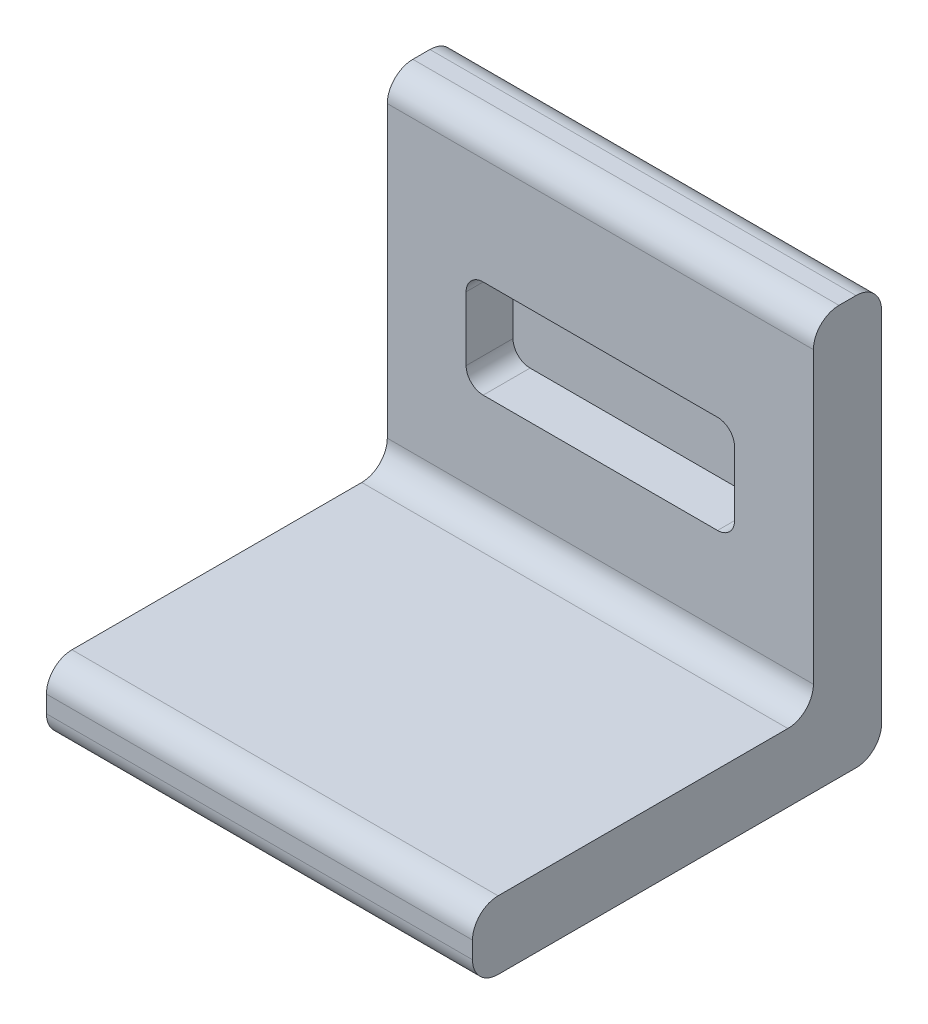
from build123d import *

# Parameters (mm, degrees)
SKETCH1_W           = 50
SKETCH1_H           = 40
BOSS_EXTRUDE1_DEPTH = 8
SKETCH2_W           = 50
SKETCH2_H           = 48
BOSS_EXTRUDE2_DEPTH = 8
SKETCH3_W           = 31.5
SKETCH3_H           = 11.5
CUT_EXTRUDE1_DEPTH  = 5.5
FILLET1_R           = 2
FILLET2_R           = 3


with BuildPart() as part:
    # Sketch1 → Boss-Extrude1 (new body)
    with BuildSketch(Plane(origin=(0, 0, 0), x_dir=(1, 0, 0), z_dir=(0, 1, 0))):
        with Locations((0, 20)):
            Rectangle(SKETCH1_W, SKETCH1_H)
    extrude(amount=BOSS_EXTRUDE1_DEPTH)

    # Sketch2 → Boss-Extrude2 (add)
    with BuildSketch(Plane(origin=(0, 0, -40), x_dir=(-1, 0, 0), z_dir=(0, 0, -1))):
        with Locations((0, 24)):
            Rectangle(SKETCH2_W, SKETCH2_H)
    extrude(amount=BOSS_EXTRUDE2_DEPTH)

    # Sketch3 → Cut-Extrude1 (cut)
    with BuildSketch(Plane.XY.offset(-40)):
        with Locations((0, 26.75)):
            Rectangle(SKETCH3_W, SKETCH3_H)
    extrude(amount=-CUT_EXTRUDE1_DEPTH, mode=Mode.SUBTRACT)

    # Fillet1
    fillet1_edges = [part.edges().sort_by_distance(p)[0] for p in [
        (-15.75, 21, -42.75),
        (-15.75, 32.5, -42.75),
        (15.75, 32.5, -42.75),
        (15.75, 21, -42.75),
    ]]
    fillet(fillet1_edges, radius=FILLET1_R)

    # Fillet2
    fillet2_edges = [part.edges().sort_by_distance(p)[0] for p in [
        (0, 48, -40),
        (0, 0, -48),
        (0, 8, -40),
        (0, 48, -48),
        (0, 0, 0),
        (0, 8, 0),
    ]]
    fillet(fillet2_edges, radius=FILLET2_R)


solid = part.part
